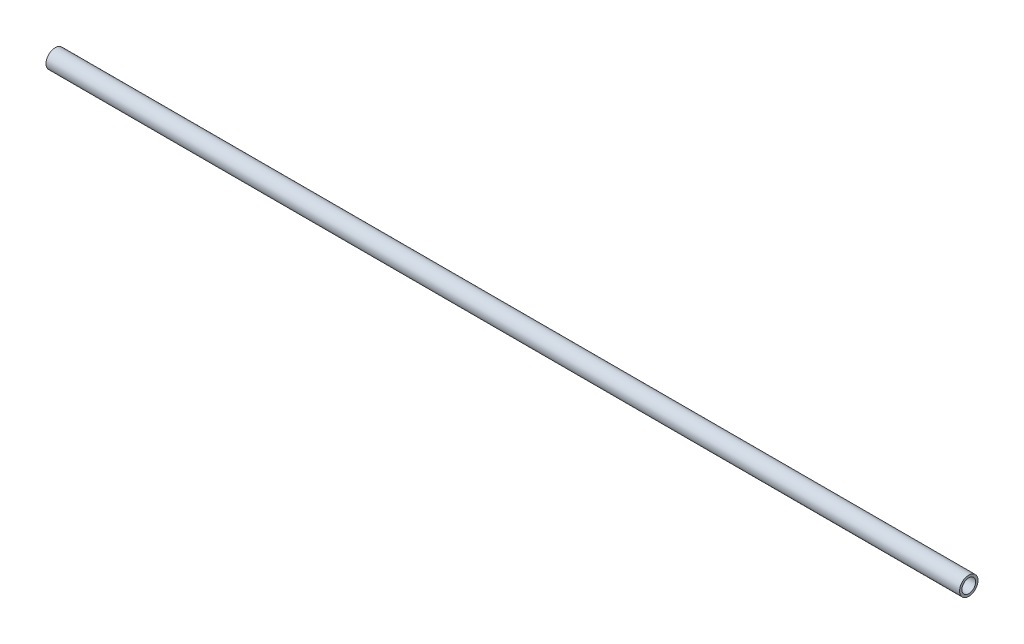
from build123d import *

# Parameters (mm, degrees)
SKETCH1_R           = 6.4135
SKETCH1_R_2         = 4.7625
BOSS_EXTRUDE1_DEPTH = 635


with BuildPart() as part:
    # Sketch1 → Boss-Extrude1 (new body)
    with BuildSketch(Plane(origin=(0, 0, 0), x_dir=(0, 0, -1), z_dir=(1, 0, 0))):
        Circle(SKETCH1_R)
        Circle(SKETCH1_R_2, mode=Mode.SUBTRACT)
    extrude(amount=BOSS_EXTRUDE1_DEPTH)


solid = part.part
